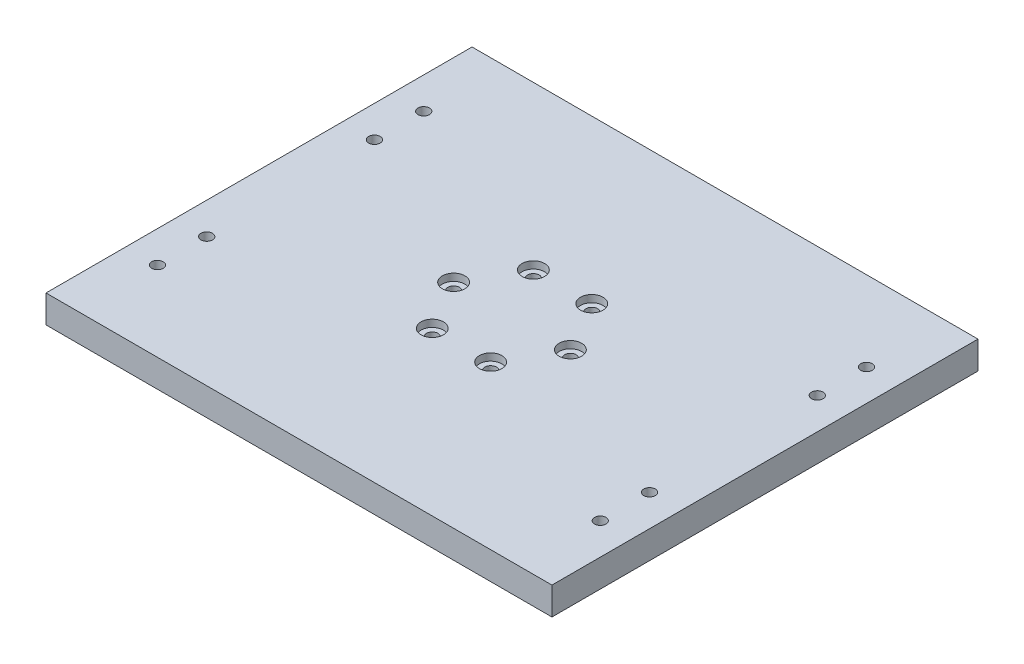
from build123d import *

# Parameters (mm, degrees)
SKETCH1_W                                = 482.6
SKETCH1_H                                = 406.4
BOSS_EXTRUDE1_DEPTH                      = 26.416
SKETCH3_R                                = 1.27
SKETCH3_R_2                              = 5.25
CUT_EXTRUDE2_DEPTH                       = 27.416
CBORE_FOR_M10_HEX_HEAD_BOLT1_D           = 11
CBORE_FOR_M10_HEX_HEAD_BOLT1_CBORE_D     = 21.48
CBORE_FOR_M10_HEX_HEAD_BOLT1_CBORE_DEPTH = 6.85
M10_CLEARANCE_HOLE1_D                    = 11


with BuildPart() as part:
    # Sketch1 → Boss-Extrude1 (new body)
    with BuildSketch(Plane(origin=(0, 0, 0), x_dir=(1, 0, 0), z_dir=(0, 1, 0))):
        Rectangle(SKETCH1_W, SKETCH1_H)
    extrude(amount=BOSS_EXTRUDE1_DEPTH)

    # Sketch3 → Cut-Extrude2 (cut, through all)
    with BuildSketch(Plane(origin=(0, 26.416, 0), x_dir=(1, 0, 0), z_dir=(0, 1, 0))):
        with Locations((-211.201, -80.01)):
            Circle(SKETCH3_R)
        with Locations((-211.201, 80.01)):
            Circle(SKETCH3_R)
        with Locations((211.201, -80.01)):
            Circle(SKETCH3_R)
        with Locations((211.201, 80.01)):
            Circle(SKETCH3_R)
        with Locations((55.7, 0)):
            Circle(SKETCH3_R_2)
        with Locations((27.85, -48.237614991)):
            Circle(SKETCH3_R_2)
        with Locations((-27.85, -48.237614991)):
            Circle(SKETCH3_R_2)
        with Locations((-55.7, 0)):
            Circle(SKETCH3_R_2)
        with Locations((-27.85, 48.237614991)):
            Circle(SKETCH3_R_2)
        with Locations((27.85, 48.237614991)):
            Circle(SKETCH3_R_2)
        with Locations((-211.201, -127)):
            Circle(SKETCH3_R)
        with Locations((211.201, -127)):
            Circle(SKETCH3_R)
        with Locations((211.201, 127)):
            Circle(SKETCH3_R)
        with Locations((-211.201, 127)):
            Circle(SKETCH3_R)
    extrude(amount=-CUT_EXTRUDE2_DEPTH, mode=Mode.SUBTRACT)

    # CBORE for M10 Hex Head Bolt1 (through all)
    with Locations(Plane(origin=(0, 26.416, 0), x_dir=(1, 0, 0), z_dir=(0, 1, 0))):
        with Locations((27.85, 48.237614991), (55.7, 0), (27.85, -48.237614991), (-27.85, -48.237614991), (-55.7, 0), (-27.85, 48.237614991)):
            CounterBoreHole(CBORE_FOR_M10_HEX_HEAD_BOLT1_D / 2, CBORE_FOR_M10_HEX_HEAD_BOLT1_CBORE_D / 2, CBORE_FOR_M10_HEX_HEAD_BOLT1_CBORE_DEPTH)

    # M10 Clearance Hole1 (through all)
    with Locations(Plane(origin=(0, 26.416, 0), x_dir=(1, 0, 0), z_dir=(0, 1, 0))):
        with Locations((-211.201, 127), (-211.201, 80.01), (-211.201, -80.01), (-211.201, -127), (211.201, -127), (211.201, -80.01), (211.201, 80.01), (211.201, 127)):
            Hole(M10_CLEARANCE_HOLE1_D / 2)


solid = part.part
